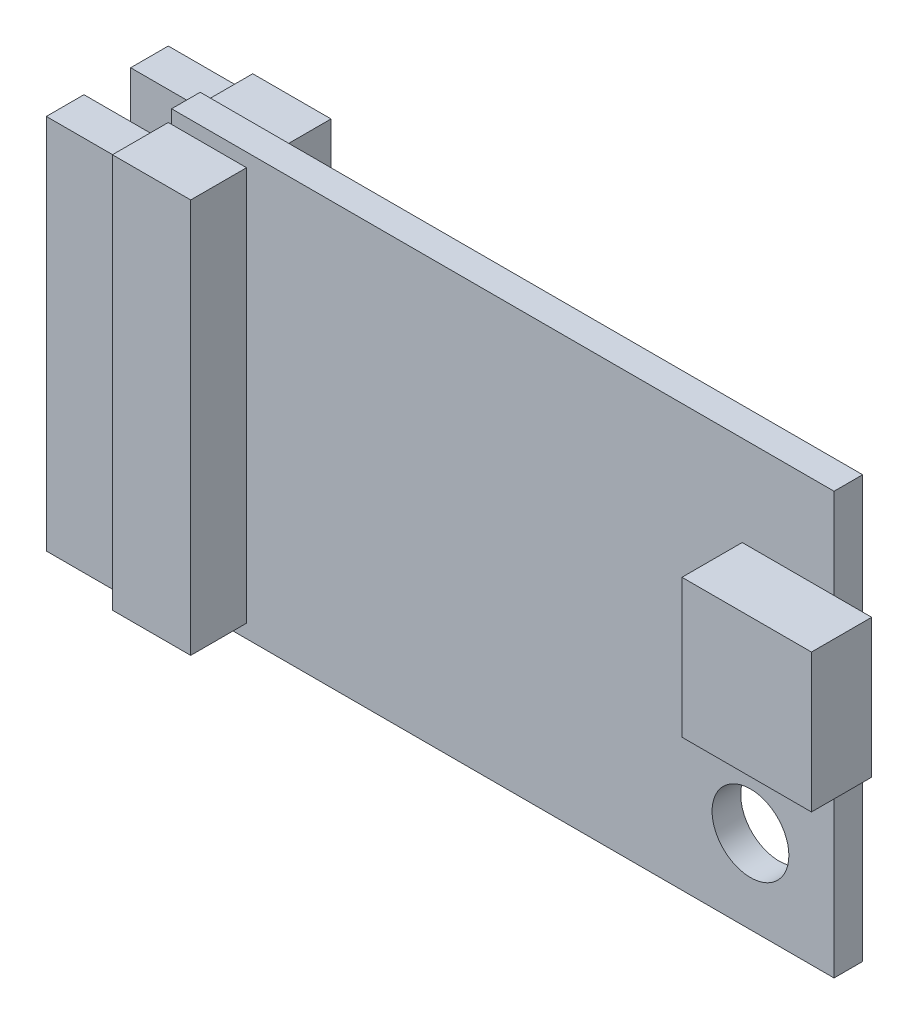
from build123d import *

# Parameters (mm, degrees)
SKETCH1_W           = 22
SKETCH1_H           = 14
SKETCH1_R           = 1.275
BOSS_EXTRUDE1_DEPTH = 0.475
SKETCH2_W           = 2.6
SKETCH2_H           = 13.1
BOSS_EXTRUDE2_DEPTH = 1.855
SKETCH3_W           = 1.25
SKETCH3_H           = 12.5
BOSS_EXTRUDE3_DEPTH = 2.5
SKETCH4_W           = 4.3
SKETCH4_H           = 4.6
BOSS_EXTRUDE4_DEPTH = 2


with BuildPart() as part:
    # Sketch1 → Boss-Extrude1 (new body, symmetric)
    with BuildSketch(Plane.XY):
        Rectangle(SKETCH1_W, SKETCH1_H)
        with Locations((8.225, -4.225)):
            Circle(SKETCH1_R, mode=Mode.SUBTRACT)
    extrude(amount=BOSS_EXTRUDE1_DEPTH, both=True)

    # Sketch2 → Boss-Extrude2 (add)
    with BuildSketch(Plane.XY.offset(0.475)):
        with Locations((-9.81, 0)):
            Rectangle(SKETCH2_W, SKETCH2_H)
    boss_extrude2 = extrude(amount=BOSS_EXTRUDE2_DEPTH)

    # Mirror1: Boss-Extrude2 across plane
    add(boss_extrude2.mirror(Plane.XY))

    # Sketch3 → Boss-Extrude3 (add)
    with BuildSketch(Plane.ZY.offset(11.11)):
        with Locations((-1.4, 0)):
            Rectangle(SKETCH3_W, SKETCH3_H)
    boss_extrude3 = extrude(amount=BOSS_EXTRUDE3_DEPTH)

    # Mirror2: Boss-Extrude3 across plane
    add(boss_extrude3.mirror(Plane.XY))

    # Sketch4 → Boss-Extrude4 (add)
    with BuildSketch(Plane.XY.offset(0.475)):
        with Locations((10.1, 1.7)):
            Rectangle(SKETCH4_W, SKETCH4_H)
    extrude(amount=BOSS_EXTRUDE4_DEPTH)


solid = part.part
